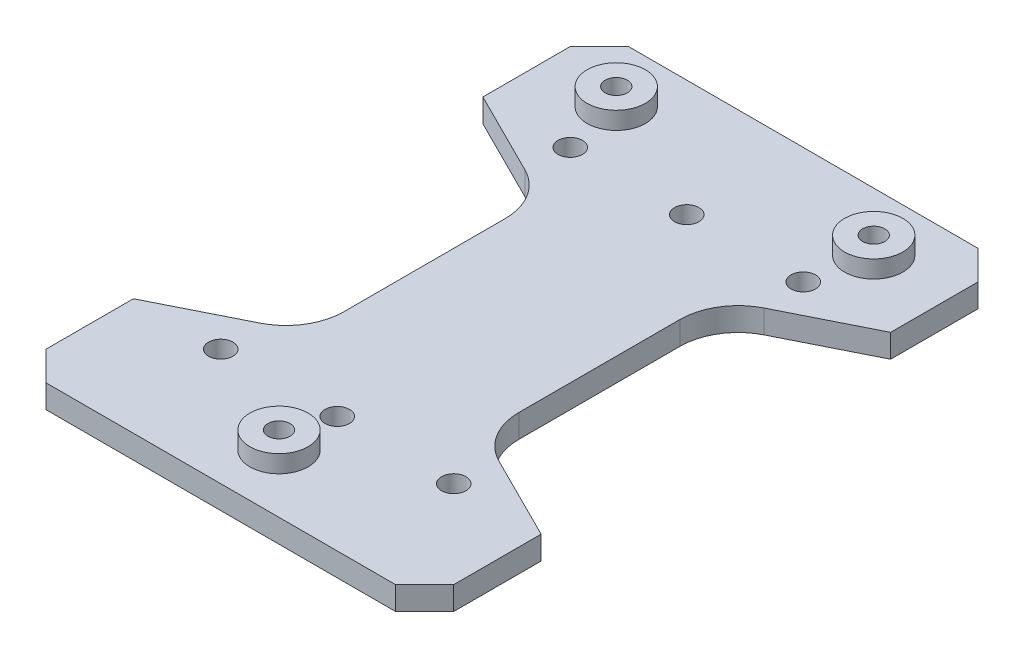
from build123d import *

# Parameters (mm, degrees)
SKETCH_1_W                  = 70
SKETCH_1_H                  = 100
EXTRUDE_1_DEPTH             = 4
SKETCH_2_R                  = 5
EXTRUDE_2_DEPTH             = 3
SKETCH_3_R                  = 1.9
CUT_EXTRUDE_1_DEPTH         = 4
SKETCH_6_R                  = 2.1
CUT_EXTRUDE_4_DEPTH         = 5
PATTERN_LINEAR_1_COUNT      = 3
PATTERN_LINEAR_1_PITCH      = 20
PATTERN_LINEAR_1_COUNT_DIR2 = 4
PATTERN_LINEAR_1_PITCH_DIR2 = 20
CUT_EXTRUDE_START           = -5
CUT_EXTRUDE_5_DEPTH         = 9
CHAMFER_1_SIZE              = 5
FILLET_1_R                  = 10


with BuildPart() as part:
    # 草圖1 → 填料-伸長1 (new body)
    with BuildSketch(Plane(origin=(0, 0, 0), x_dir=(1, 0, 0), z_dir=(0, 1, 0))):
        Rectangle(SKETCH_1_W, SKETCH_1_H)
    extrude(amount=EXTRUDE_1_DEPTH)

    # 草圖2 → 填料-伸長2 (add)
    with BuildSketch(Plane(origin=(0, 4, 0), x_dir=(1, 0, 0), z_dir=(0, 1, 0))):
        with Locations((-22.1, 40)):
            Circle(SKETCH_2_R)
        with Locations((22.1, 40)):
            Circle(SKETCH_2_R)
        with Locations((0, -40)):
            Circle(SKETCH_2_R)
    extrude(amount=EXTRUDE_2_DEPTH)

    # 草圖3 → 除料-伸長1 (cut)
    with BuildSketch(Plane(origin=(0, 7, 0), x_dir=(1, 0, 0), z_dir=(0, 1, 0))):
        with Locations((-22.1, 40)):
            Circle(SKETCH_3_R)
        with Locations((22.1, 40)):
            Circle(SKETCH_3_R)
        with Locations((0, -40)):
            Circle(SKETCH_3_R)
    extrude(amount=-CUT_EXTRUDE_1_DEPTH, mode=Mode.SUBTRACT)

    # 草圖6 → 除料-伸長4 (cut, through all)
    with BuildSketch(Plane(origin=(0, 4, 0), x_dir=(1, 0, 0), z_dir=(0, 1, 0))):
        with Locations((-20, 30)):
            Circle(SKETCH_6_R)
    cut_extrude_4 = extrude(amount=-CUT_EXTRUDE_4_DEPTH, mode=Mode.SUBTRACT)

    # 直線複製排列1: Cut-Extrude 4 3 × 4, 6 skipped
    with Locations(*[(i * PATTERN_LINEAR_1_PITCH, 0, j * PATTERN_LINEAR_1_PITCH_DIR2) for i in range(PATTERN_LINEAR_1_COUNT) for j in range(PATTERN_LINEAR_1_COUNT_DIR2) if (i, j) not in ((0, 0), (0, 1), (0, 2), (1, 1), (1, 2), (2, 1), (2, 2))]):
        add(cut_extrude_4, mode=Mode.SUBTRACT)

    # 草圖7 → 除料-伸長5 (cut)
    with BuildSketch(Plane(origin=(0, 4, 0), x_dir=(1, 0, 0), z_dir=(0, 1, 0)).offset(CUT_EXTRUDE_START)):
        Polygon((-35, 30), (-15, 20), (-15, -20), (-35, -30), align=None)
    cut_extrude_5 = extrude(amount=CUT_EXTRUDE_5_DEPTH, mode=Mode.SUBTRACT)

    # 鏡射1: 除料-伸長5 across plane
    add(cut_extrude_5.mirror(Plane(origin=(0, 0, 0), x_dir=(0, 0, 1), z_dir=(1, 0, 0))), mode=Mode.SUBTRACT)

    # 導角1
    chamfer_1_edges = [part.edges().sort_by_distance(p)[0] for p in [
        (35, 2, 50),
        (-35, 2, 50),
        (-35, 2, -50),
        (35, 2, -50),
    ]]
    chamfer(chamfer_1_edges, length=CHAMFER_1_SIZE)

    # 圓角1
    fillet_1_edges = [part.edges().sort_by_distance(p)[0] for p in [
        (-15, 2, -20),
        (-15, 2, 20),
        (15, 2, 20),
        (15, 2, -20),
    ]]
    fillet(fillet_1_edges, radius=FILLET_1_R)


solid = part.part
